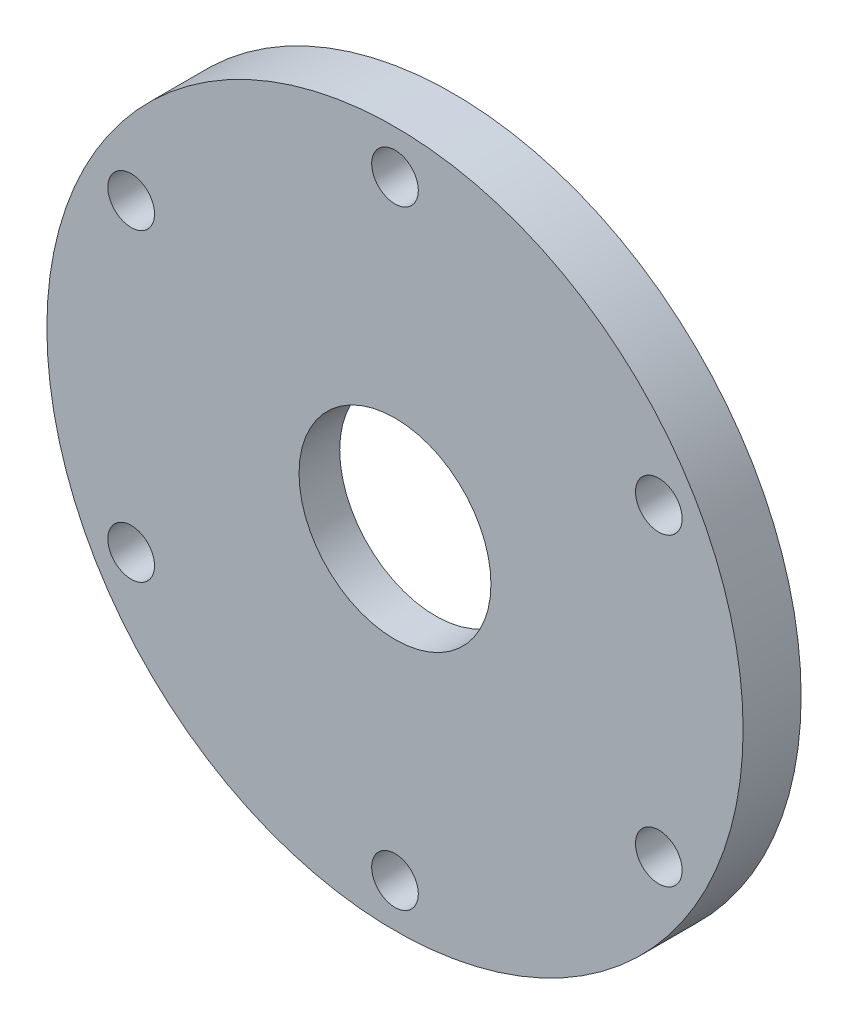
from build123d import *

# Parameters (mm, degrees)
SKETCH1_R           = 38.1
SKETCH1_R_2         = 10.5
BOSS_EXTRUDE1_DEPTH = 3.175
SKETCH6_R           = 17.75000006
CUT_EXTRUDE2_DEPTH  = 1.500000048
SKETCH8_R           = 2.5527
CUT_EXTRUDE3_DEPTH  = 7.35
SKETCH9_R           = 14.09889992
CUT_EXTRUDE4_DEPTH  = 0.4


with BuildPart() as part:
    # Sketch1 → Boss-Extrude1 (new body, symmetric)
    with BuildSketch(Plane.XY):
        Circle(SKETCH1_R)
        Circle(SKETCH1_R_2, mode=Mode.SUBTRACT)
    extrude(amount=BOSS_EXTRUDE1_DEPTH, both=True)

    # Sketch6 → Cut-Extrude2 (cut)
    with BuildSketch(Plane(origin=(0, 0, -3.175), x_dir=(-1, 0, 0), z_dir=(0, 0, -1))):
        Circle(SKETCH6_R)
    extrude(amount=-CUT_EXTRUDE2_DEPTH, mode=Mode.SUBTRACT)

    # Sketch8 → Cut-Extrude3 (cut, through all)
    with BuildSketch(Plane.XY.offset(3.175)):
        with Locations((-28.871121899, 16.66875)):
            Circle(SKETCH8_R)
        with Locations((0, 33.3375)):
            Circle(SKETCH8_R)
        with Locations((28.871121899, 16.66875)):
            Circle(SKETCH8_R)
        with Locations((28.871121899, -16.66875)):
            Circle(SKETCH8_R)
        with Locations((0, -33.3375)):
            Circle(SKETCH8_R)
        with Locations((-28.871121899, -16.66875)):
            Circle(SKETCH8_R)
    extrude(amount=-CUT_EXTRUDE3_DEPTH, mode=Mode.SUBTRACT)

    # Sketch9 → Cut-Extrude4 (cut)
    with BuildSketch(Plane(origin=(0, 0, -1.674999952), x_dir=(-1, 0, 0), z_dir=(0, 0, -1))):
        Circle(SKETCH9_R)
    extrude(amount=-CUT_EXTRUDE4_DEPTH, mode=Mode.SUBTRACT)


solid = part.part
